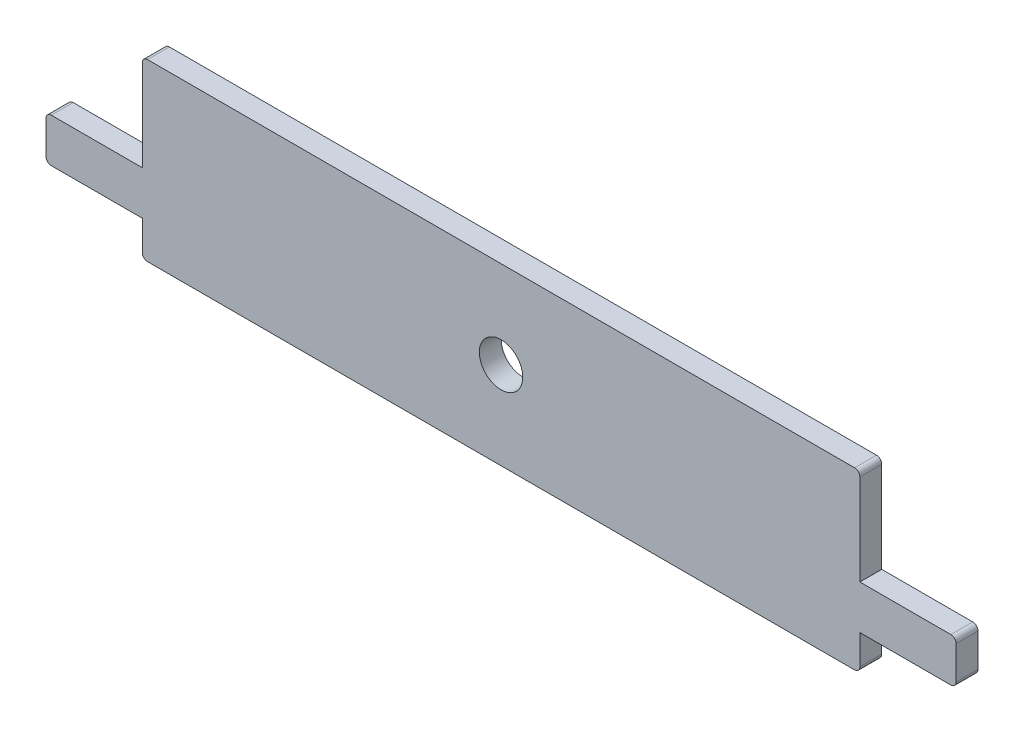
from build123d import *

# Parameters (mm, degrees)
SKETCH1_R           = 3.1496
BOSS_EXTRUDE1_DEPTH = 3.175


with BuildPart() as part:
    # Sketch1 → Boss-Extrude1 (new body)
    with BuildSketch(Plane.XY):
        with BuildLine():
            Line((0.762, 0), (103.378, 0))
            ThreePointArc((103.378, 0), (103.916815367, 0.223184633), (104.14, 0.762))
            Line((104.14, 0.762), (104.14, 5.08))
            Line((104.14, 5.08), (117.348, 5.08))
            ThreePointArc((117.348, 5.08), (117.886815367, 5.303184633), (118.11, 5.842))
            Line((118.11, 5.842), (118.11, 10.668))
            ThreePointArc((118.11, 10.668), (117.886815367, 11.206815367), (117.348, 11.43))
            Line((117.348, 11.43), (104.14, 11.43))
            Line((104.14, 11.43), (104.14, 24.638))
            ThreePointArc((104.14, 24.638), (103.916815367, 25.176815367), (103.378, 25.4))
            Line((103.378, 25.4), (0.762, 25.4))
            ThreePointArc((0.762, 25.4), (0.223184633, 25.176815367), (0, 24.638))
            Line((0, 24.638), (0, 11.43))
            Line((0, 11.43), (-13.208, 11.43))
            ThreePointArc((-13.208, 11.43), (-13.746815367, 11.206815367), (-13.97, 10.668))
            Line((-13.97, 10.668), (-13.97, 5.842))
            ThreePointArc((-13.97, 5.842), (-13.746815367, 5.303184633), (-13.208, 5.08))
            Line((-13.208, 5.08), (0, 5.08))
            Line((0, 5.08), (0, 0.762))
            ThreePointArc((0, 0.762), (0.223184633, 0.223184633), (0.762, 0))
        make_face()
        with Locations((52.07, 12.7)):
            Circle(SKETCH1_R, mode=Mode.SUBTRACT)
    extrude(amount=BOSS_EXTRUDE1_DEPTH)


solid = part.part
